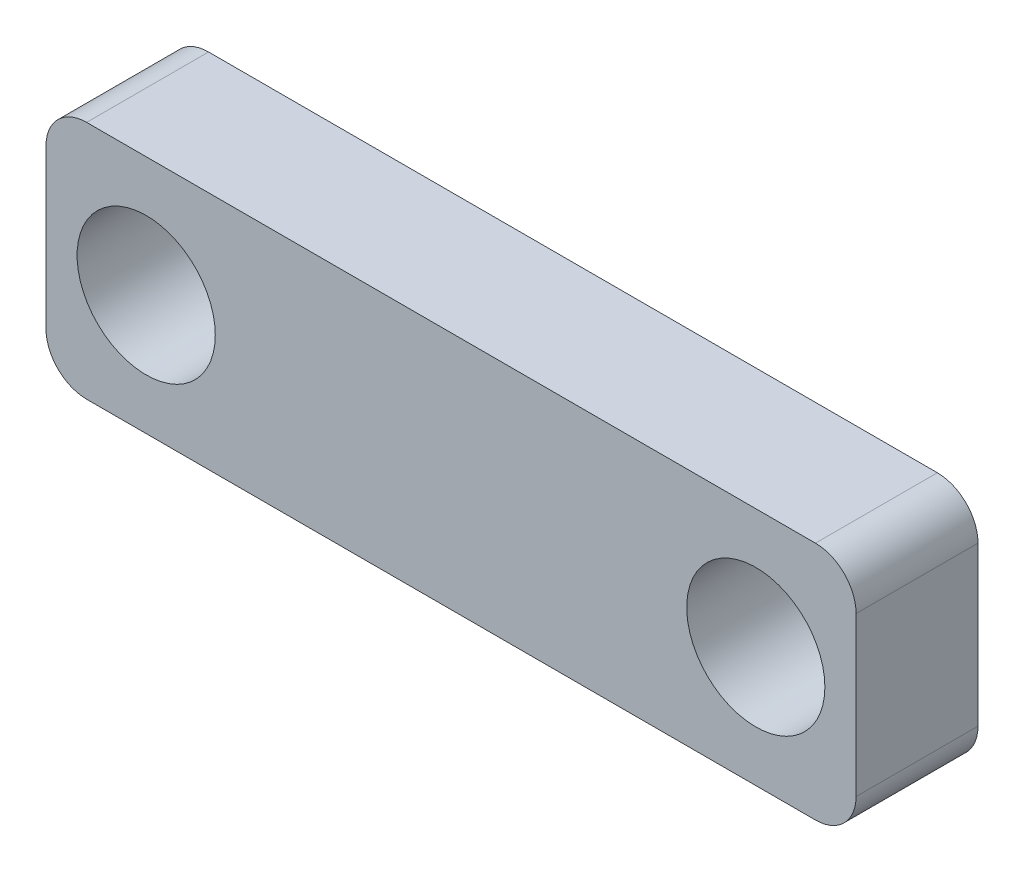
from build123d import *

# Parameters (mm, degrees)
SKETCH2_W                = 19.932631385
SKETCH2_H                = 5.9
BOSS_EXTRUDE1_DEPTH      = 3
FILLET1_R                = 1
M3_CLEARANCE_HOLE1_D     = 3.4
M3_CLEARANCE_HOLE1_DEPTH = 16.5
M3_CLEARANCE_HOLE1_TIP   = 1.021463052


with BuildPart() as part:
    # Sketch2 → Boss-Extrude1 (new body)
    with BuildSketch(Plane.XY.offset(133.365661293)):
        with Locations((-21.255805031, 37.989811256)):
            Rectangle(SKETCH2_W, SKETCH2_H)
    extrude(amount=BOSS_EXTRUDE1_DEPTH)

    # Fillet1
    fillet1_edges = [part.edges().sort_by_distance(p)[0] for p in [
        (-31.222120723, 40.939811256, 134.865661293),
        (-11.289489338, 40.939811256, 134.865661293),
        (-11.289489338, 35.039811256, 134.865661293),
        (-31.222120723, 35.039811256, 134.865661293),
    ]]
    fillet(fillet1_edges, radius=FILLET1_R)

    # M3 Clearance Hole1
    with Locations(Plane.XY.offset(136.365661293)):
        with Locations((-28.757120723, 37.989811256), (-13.757120723, 37.989811256)):
            Hole(M3_CLEARANCE_HOLE1_D / 2, depth=M3_CLEARANCE_HOLE1_DEPTH)
            with Locations((0, 0, -(M3_CLEARANCE_HOLE1_DEPTH + M3_CLEARANCE_HOLE1_TIP / 2))):  # 118° drill point
                Cone(0, M3_CLEARANCE_HOLE1_D / 2, M3_CLEARANCE_HOLE1_TIP, mode=Mode.SUBTRACT)


solid = part.part
